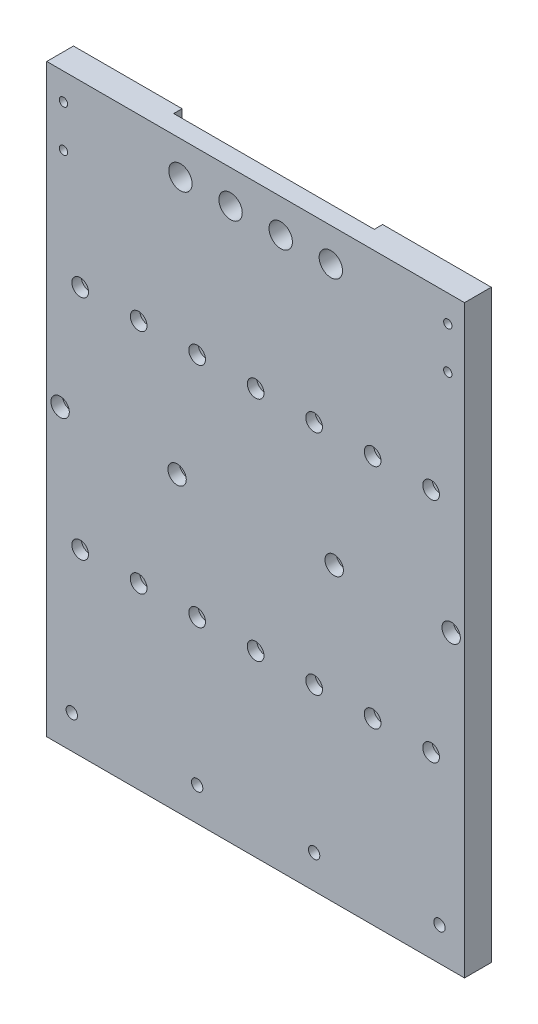
from build123d import *

# Parameters (mm, degrees)
SKETCH_1_W                  = 250
SKETCH_1_H                  = 350
EXTRUDE_1_DEPTH             = 16
HOLE_WIZARD_0_D             = 5.5
HOLE_WIZARD_0_DEPTH         = 22.25
HOLE_WIZARD_0_CBORE_D       = 10
HOLE_WIZARD_0_CBORE_DEPTH   = 5.7
HOLE_WIZARD_0_TIP           = 1.652366702
HOLE_WIZARD_0_2_D           = 6.6
HOLE_WIZARD_0_2_DEPTH       = 16
HOLE_WIZARD_0_2_CBORE_D     = 11
HOLE_WIZARD_0_2_CBORE_DEPTH = 6.8
MM_1_D                      = 6.8
MM_1_DEPTH                  = 22.25
MM_1_TIP                    = 2.042926105
HOLE_WIZARD_M6_1_D          = 5
HOLE_WIZARD_M6_1_DEPTH      = 20
HOLE_WIZARD_M6_1_TIP        = 1.502151548
MM_2_D                      = 14
MM_2_DEPTH                  = 15
MM_2_TIP                    = 4.206024333
SKETCH_12_W                 = 120
SKETCH_12_H                 = 29
CUT_EXTRUDE_1_DEPTH         = 5
FILLET_1_R                  = 3


with BuildPart() as part:
    # 草图1 → 凸台-拉伸1 (new body)
    with BuildSketch(Plane.XY):
        Rectangle(SKETCH_1_W, SKETCH_1_H)
    extrude(amount=EXTRUDE_1_DEPTH)

    # Hole Wizard 0
    with Locations(Plane(origin=(-70, 68, 16), x_dir=(1, 0, 0), z_dir=(0, 0, 1))):
        with Locations((0, 0), (35, 0), (70, 0), (105, 0), (140, 0), (-35, 0), (175, 0), (-35, -136), (0, -136), (35, -136), (70, -136), (105, -136), (140, -136), (175, -136)):
            CounterBoreHole(HOLE_WIZARD_0_D / 2, HOLE_WIZARD_0_CBORE_D / 2, HOLE_WIZARD_0_CBORE_DEPTH, depth=HOLE_WIZARD_0_DEPTH)
            with Locations((0, 0, -(HOLE_WIZARD_0_DEPTH + HOLE_WIZARD_0_TIP / 2))):  # 118° drill point
                Cone(0, HOLE_WIZARD_0_D / 2, HOLE_WIZARD_0_TIP, mode=Mode.SUBTRACT)

    # Hole Wizard 0 2
    with Locations(Plane(origin=(-47, 0, 16), x_dir=(1, 0, 0), z_dir=(0, 0, 1))):
        with Locations((0, 0), (94, 0), (-70, 0), (164, 0)):
            CounterBoreHole(HOLE_WIZARD_0_2_D / 2, HOLE_WIZARD_0_2_CBORE_D / 2, HOLE_WIZARD_0_2_CBORE_DEPTH, depth=HOLE_WIZARD_0_2_DEPTH)

    # 大小mm 暗销孔1
    with Locations(Plane(origin=(-110, -155, 16), x_dir=(1, 0, 0), z_dir=(0, 0, 1))):
        with Locations((0, 0), (75, 0), (145, 0), (220, 0)):
            Hole(MM_1_D / 2, depth=MM_1_DEPTH)
            with Locations((0, 0, -(MM_1_DEPTH + MM_1_TIP / 2))):  # 118° drill point
                Cone(0, MM_1_D / 2, MM_1_TIP, mode=Mode.SUBTRACT)

    # M6 螺纹孔1
    with Locations(Plane(origin=(-115, 159, 16), x_dir=(1, 0, 0), z_dir=(0, 0, 1))):
        with Locations((0, 0), (0, -25), (230, 0), (230, -25)):
            Hole(HOLE_WIZARD_M6_1_D / 2, depth=HOLE_WIZARD_M6_1_DEPTH)
            with Locations((0, 0, -(HOLE_WIZARD_M6_1_DEPTH + HOLE_WIZARD_M6_1_TIP / 2))):  # 118° drill point
                Cone(0, HOLE_WIZARD_M6_1_D / 2, HOLE_WIZARD_M6_1_TIP, mode=Mode.SUBTRACT)

    # 大小mm 暗销槽口2
    with Locations(Plane(origin=(-45, 155, 16), x_dir=(1, 0, 0), z_dir=(0, 0, 1))):
        with Locations((0, 0), (30, 0), (60, 0), (90, 0)):
            Hole(MM_2_D / 2, depth=MM_2_DEPTH)
            with Locations((0, 0, -(MM_2_DEPTH + MM_2_TIP / 2))):  # 118° drill point
                Cone(0, MM_2_D / 2, MM_2_TIP, mode=Mode.SUBTRACT)

    # 草图12 → 切除-拉伸1 (cut)
    with BuildSketch(Plane(origin=(0, 0, 0), x_dir=(-1, 0, 0), z_dir=(0, 0, -1))):
        with Locations((0, 160.5)):
            Rectangle(SKETCH_12_W, SKETCH_12_H)
    extrude(amount=-CUT_EXTRUDE_1_DEPTH, mode=Mode.SUBTRACT)

    # 圆角1
    fillet_1_edges = [part.edges().sort_by_distance(p)[0] for p in [
        (60, 146, 2.5),
        (-60, 146, 2.5),
    ]]
    fillet(fillet_1_edges, radius=FILLET_1_R)


solid = part.part
